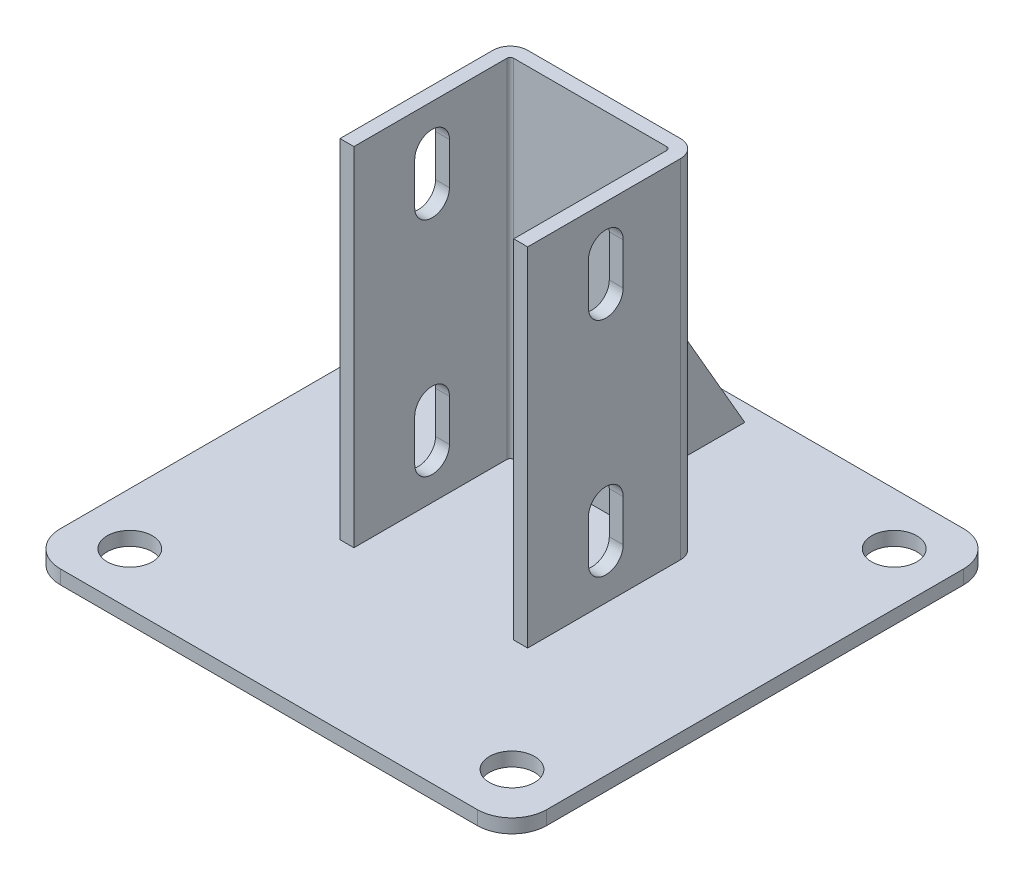
from build123d import *

# Parameters (mm, degrees)
SKETCH_2_W          = 140
SKETCH_2_H          = 140
EXTRUDE_1_DEPTH     = 4
EXTRUDE_1_2_DEPTH   = 100
EXTRUDE_2_DEPTH     = 2
CUT_EXTRUDE_1_DEPTH = 98
SKETCH_6_R          = 6.5
CUT_EXTRUDE_2_DEPTH = 5
FILLET_1_R          = 10


with BuildPart() as part:
    # Эскиз2 → Extrude 1 (new body)
    with BuildSketch(Plane(origin=(0, 0, 0), x_dir=(1, 0, 0), z_dir=(0, 1, 0))):
        Rectangle(SKETCH_2_W, SKETCH_2_H)
    extrude(amount=EXTRUDE_1_DEPTH)

    # Эскиз3 → Extrude 1 2 (add)
    with BuildSketch(Plane(origin=(0, 4, 0), x_dir=(1, 0, 0), z_dir=(0, 1, 0))):
        with BuildLine():
            Line((-23, -22.5), (-23, 21.5))
            ThreePointArc((-23, 21.5), (-22.707106781, 22.207106781), (-22, 22.5))
            Line((-22, 22.5), (22, 22.5))
            ThreePointArc((22, 22.5), (22.707106781, 22.207106781), (23, 21.5))
            Line((23, 21.5), (23, -22.5))
            Line((23, -22.5), (27, -22.5))
            Line((27, -22.5), (27, 21.5))
            ThreePointArc((27, 21.5), (25.535533906, 25.035533906), (22, 26.5))
            Line((22, 26.5), (-22, 26.5))
            ThreePointArc((-22, 26.5), (-25.535533906, 25.035533906), (-27, 21.5))
            Line((-27, 21.5), (-27, -22.5))
            Line((-27, -22.5), (-23, -22.5))
        make_face()
    extrude(amount=EXTRUDE_1_2_DEPTH)

    # Эскиз4 → Бобышка-Вытянуть2 (add, symmetric)
    with BuildSketch(Plane(origin=(0, 0, 0), x_dir=(0, 0, -1), z_dir=(1, 0, 0))):
        Polygon((26.5, 70.683956091), (65, 4), (26.5, 4), align=None)
    extrude(amount=EXTRUDE_2_DEPTH, both=True)

    # Эскиз5 → Вырез-Вытянуть1 (cut, through all)
    with BuildSketch(Plane(origin=(27, 0, 0), x_dir=(0, 0, -1), z_dir=(1, 0, 0))):
        with BuildLine():
            Line((5, 92), (5, 80))
            ThreePointArc((5, 80), (0, 75), (-5, 80))
            Line((-5, 80), (-5, 92))
            ThreePointArc((-5, 92), (0, 97), (5, 92))
        make_face()
        with BuildLine():
            Line((5, 28), (5, 16))
            ThreePointArc((5, 16), (0, 11), (-5, 16))
            Line((-5, 16), (-5, 28))
            ThreePointArc((-5, 28), (0, 33), (5, 28))
        make_face()
    extrude(amount=-CUT_EXTRUDE_1_DEPTH, mode=Mode.SUBTRACT)

    # Эскиз6 → Вырез-Вытянуть2 (cut, through all)
    with BuildSketch(Plane(origin=(0, 4, 0), x_dir=(1, 0, 0), z_dir=(0, 1, 0))):
        with Locations(Location((-55, 55, 0), (0, 0, 270))):  # turned: the seam where the file's is
            Circle(SKETCH_6_R)
        with Locations(Location((-55, -55, 0), (0, 0, 270))):  # turned: the seam where the file's is
            Circle(SKETCH_6_R)
        with Locations(Location((55, 55, 0), (0, 0, 270))):  # turned: the seam where the file's is
            Circle(SKETCH_6_R)
        with Locations(Location((55, -55, 0), (0, 0, 270))):  # turned: the seam where the file's is
            Circle(SKETCH_6_R)
    extrude(amount=-CUT_EXTRUDE_2_DEPTH, mode=Mode.SUBTRACT)

    # Скругление1
    fillet_1_edges = [part.edges().sort_by_distance(p)[0] for p in [
        (70, 2, 70),
        (-70, 2, 70),
        (-70, 2, -70),
        (70, 2, -70),
    ]]
    fillet(fillet_1_edges, radius=FILLET_1_R)


solid = part.part
